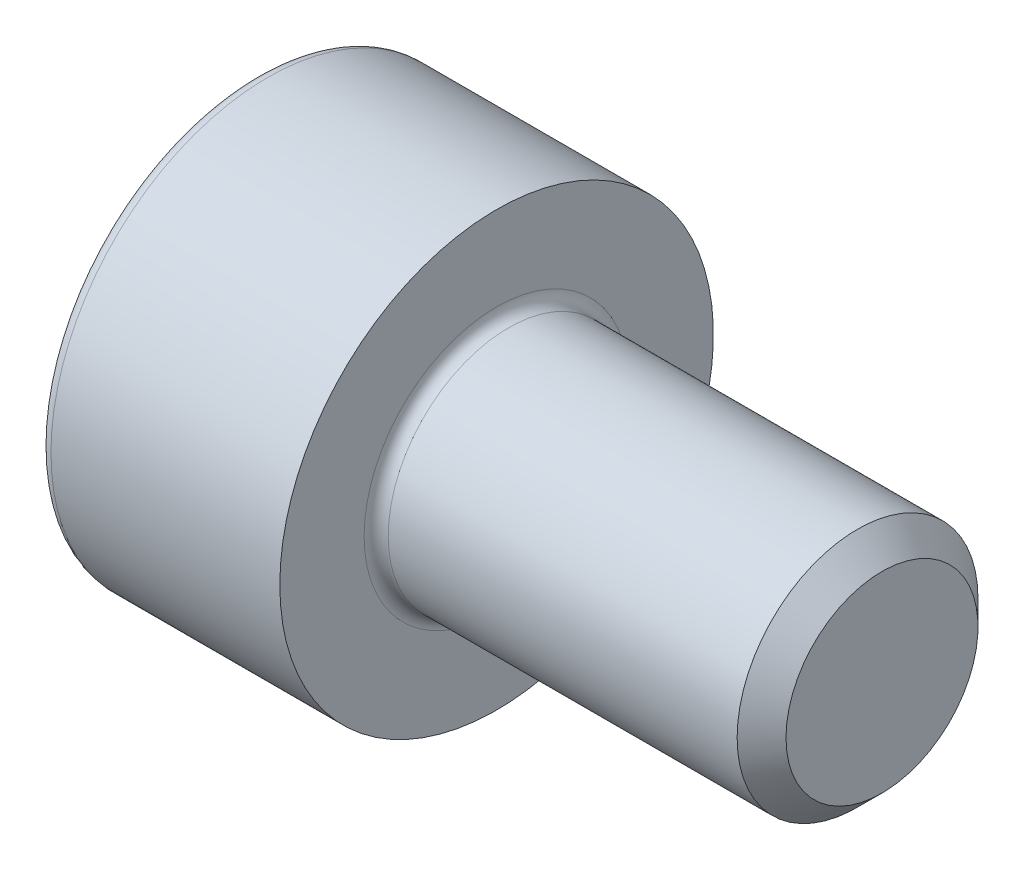
from build123d import *

# Parameters (mm, degrees)
CUT_EXTRUDE1_DEPTH = 1.1


with BuildPart() as part:
    # Sketch1 → Revolve1 (revolve)
    with BuildSketch(Plane.XY):
        with BuildLine():
            Line((3.7465, 1.25), (0.125, 1.25))
            ThreePointArc((0.125, 1.25), (0.036611652, 1.286611652), (0, 1.375))
            Line((0, 1.375), (0, 2.25))
            Line((0, 2.25), (-2.375, 2.25))
            ThreePointArc((-2.375, 2.25), (-2.463388348, 2.213388348), (-2.5, 2.125))
            Line((-2.5, 2.125), (-2.5, 0))
            Line((-2.5, 0), (4, 0))
            Line((4, 0), (4, 0.9965))
            Line((4, 0.9965), (3.7465, 1.25))
        make_face()
    revolve(axis=Axis((-2.5, 0, 0), (1, 0, 0)))

    # Sketch2 → Cut-Extrude1 (cut)
    with BuildSketch(Plane.ZY.offset(2.5)):
        Polygon((1.025, 0.591784026), (0, 1.183568052), (-1.025, 0.591784026), (-1.025, -0.591784026), (0, -1.183568052), (1.025, -0.591784026), align=None)
    extrude(amount=-CUT_EXTRUDE1_DEPTH, mode=Mode.SUBTRACT)


solid = part.part
